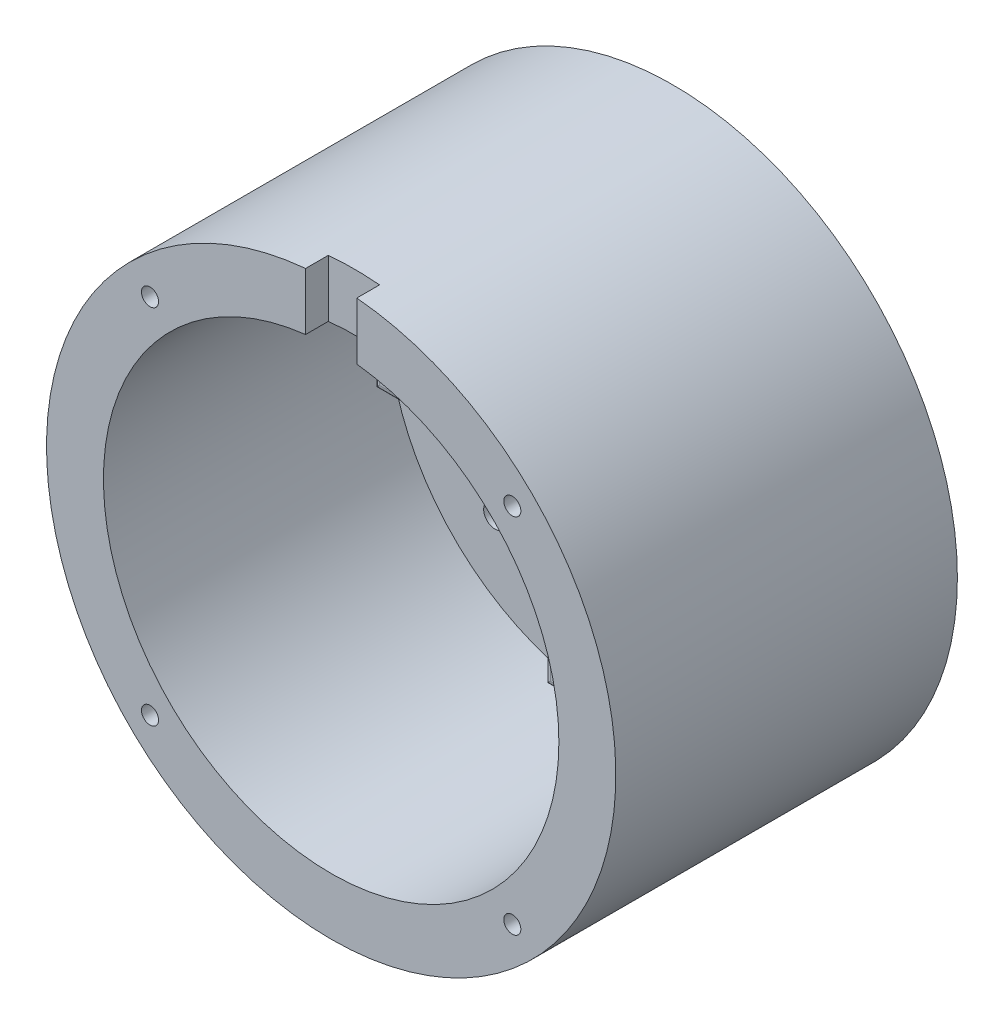
from build123d import *

# Parameters (mm, degrees)
CROQUIS1_R              = 50
CROQUIS1_R_2            = 17.75
SALIENTE_EXTRUIR1_DEPTH = 70
CROQUIS2_R              = 40
CORTAR_EXTRUIR1_DEPTH   = 50
CROQUIS4_R              = 40
CROQUIS4_R_2            = 17.75
CORTAR_EXTRUIR3_DEPTH   = 10
CROQUIS5_R              = 2
CORTAR_EXTRUIR4_DEPTH   = 11
CROQUIS6_R              = 5
CORTAR_EXTRUIR5_DEPTH   = 5
REDONDEO2_R             = 1
CORTAR_EXTRUIR7_START   = -10
CROQUIS8_W              = 9
CROQUIS8_H              = 20
CORTAR_EXTRUIR7_DEPTH   = 4
CROQUIS9_R              = 52.339140615
CORTAR_EXTRUIR8_DEPTH   = 10
CROQUIS10_R             = 1.5
CORTAR_EXTRUIR9_DEPTH   = 30


with BuildPart() as part:
    # Croquis1 → Saliente-Extruir1 (new body)
    with BuildSketch(Plane.XY):
        Circle(CROQUIS1_R)
        Circle(CROQUIS1_R_2, mode=Mode.SUBTRACT)
    extrude(amount=SALIENTE_EXTRUIR1_DEPTH)

    # Croquis2 → Cortar-Extruir1 (cut)
    with BuildSketch(Plane.XY.offset(70)):
        Circle(CROQUIS2_R)
    extrude(amount=-CORTAR_EXTRUIR1_DEPTH, mode=Mode.SUBTRACT)

    # Croquis4 → Cortar-Extruir3 (cut)
    with BuildSketch(Plane.XY.offset(20)):
        Circle(CROQUIS4_R)
        with BuildLine():
            Line((-2.5, 27.386127875), (-2.5, 32.5))
            Line((-2.5, 32.5), (2.5, 32.5))
            Line((2.5, 32.5), (2.5, 27.386127875))
            ThreePointArc((2.5, 27.386127875), (19.445436483, 19.445436483), (27.386127875, 2.5))
            Line((27.386127875, 2.5), (32.5, 2.5))
            Line((32.5, 2.5), (32.5, -2.5))
            Line((32.5, -2.5), (27.386127875, -2.5))
            ThreePointArc((27.386127875, -2.5), (19.445436483, -19.445436483), (2.5, -27.386127875))
            Line((2.5, -27.386127875), (2.5, -32.5))
            Line((2.5, -32.5), (-2.5, -32.5))
            Line((-2.5, -32.5), (-2.5, -27.386127875))
            ThreePointArc((-2.5, -27.386127875), (-19.445436483, -19.445436483), (-27.386127875, -2.5))
            Line((-27.386127875, -2.5), (-32.5, -2.5))
            Line((-32.5, -2.5), (-32.5, 2.5))
            Line((-32.5, 2.5), (-27.386127875, 2.5))
            ThreePointArc((-27.386127875, 2.5), (-19.445436483, 19.445436483), (-2.5, 27.386127875))
        make_face(mode=Mode.SUBTRACT)
        with BuildLine():
            Line((-2.5, 22.5), (-2.5, 27.386127875))
            ThreePointArc((-2.5, 27.386127875), (-19.445436483, 19.445436483), (-27.386127875, 2.5))
            Line((-27.386127875, 2.5), (-22.5, 2.5))
            Line((-22.5, 2.5), (-22.5, -2.5))
            Line((-22.5, -2.5), (-27.386127875, -2.5))
            ThreePointArc((-27.386127875, -2.5), (-19.445436483, -19.445436483), (-2.5, -27.386127875))
            Line((-2.5, -27.386127875), (-2.5, -22.5))
            Line((-2.5, -22.5), (2.5, -22.5))
            Line((2.5, -22.5), (2.5, -27.386127875))
            ThreePointArc((2.5, -27.386127875), (19.445436483, -19.445436483), (27.386127875, -2.5))
            Line((27.386127875, -2.5), (22.5, -2.5))
            Line((22.5, -2.5), (22.5, 2.5))
            Line((22.5, 2.5), (27.386127875, 2.5))
            ThreePointArc((27.386127875, 2.5), (19.445436483, 19.445436483), (2.5, 27.386127875))
            Line((2.5, 27.386127875), (2.5, 22.5))
            Line((2.5, 22.5), (-2.5, 22.5))
        make_face()
        Circle(CROQUIS4_R_2, mode=Mode.SUBTRACT)
    extrude(amount=-CORTAR_EXTRUIR3_DEPTH, mode=Mode.SUBTRACT)

    # Croquis5 → Cortar-Extruir4 (cut, through all)
    with BuildSketch(Plane.XY.offset(10)):
        with Locations((21.213203436, 21.213203436)):
            Circle(CROQUIS5_R)
        with Locations((21.213203436, -21.213203436)):
            Circle(CROQUIS5_R)
        with Locations((-21.213203436, -21.213203436)):
            Circle(CROQUIS5_R)
        with Locations((-21.213203436, 21.213203436)):
            Circle(CROQUIS5_R)
    extrude(amount=-CORTAR_EXTRUIR4_DEPTH, mode=Mode.SUBTRACT)

    # Croquis6 → Cortar-Extruir5 (cut)
    with BuildSketch(Plane(origin=(0, 0, 0), x_dir=(-1, 0, 0), z_dir=(0, 0, -1))):
        with Locations((-21.213203436, 21.213203436)):
            Circle(CROQUIS6_R)
        with Locations((21.486974797, 21.486974797)):
            Circle(CROQUIS6_R)
        with Locations((21.760746158, -21.213203436)):
            Circle(CROQUIS6_R)
        with Locations((-20.939432074, -21.486974797)):
            Circle(CROQUIS6_R)
    extrude(amount=-CORTAR_EXTRUIR5_DEPTH, mode=Mode.SUBTRACT)

    # Redondeo2
    redondeo2_edges = [part.edges().sort_by_distance(p)[0] for p in [
        (-40, 0, 70),
        (-22.5, 0, 20),
        (2.5, -27.5, 20),
        (32.5, 0, 20),
        (27.5, 2.5, 20),
        (-2.5, 27.5, 20),
        (-27.5, -2.5, 20),
        (0, -22.5, 20),
        (0, 22.5, 20),
        (2.5, 27.5, 20),
        (0, 32.5, 20),
        (27.5, -2.5, 20),
        (22.5, 0, 20),
        (-2.5, -27.5, 20),
        (0, -32.5, 20),
        (-32.5, 0, 20),
        (-27.5, 2.5, 20),
        (-50, 0, 70),
    ]]
    fillet(redondeo2_edges, radius=REDONDEO2_R)

    # Croquis8 → Cortar-Extruir7 (cut)
    with BuildSketch(Plane.XY.offset(70).offset(CORTAR_EXTRUIR7_START)):
        with Locations((0, 45)):
            Rectangle(CROQUIS8_W, CROQUIS8_H)
    extrude(amount=-CORTAR_EXTRUIR7_DEPTH, mode=Mode.SUBTRACT)

    # Croquis9 → Cortar-Extruir8 (cut)
    with BuildSketch(Plane.XY.offset(70)):
        Circle(CROQUIS9_R)
    extrude(amount=-CORTAR_EXTRUIR8_DEPTH, mode=Mode.SUBTRACT)

    # Croquis10 → Cortar-Extruir9 (cut)
    with BuildSketch(Plane.XY.offset(60)):
        with Locations((31.819805153, 31.819805153)):
            Circle(CROQUIS10_R)
        with Locations((31.819805153, -31.819805153)):
            Circle(CROQUIS10_R)
        with Locations((-31.819805153, -31.819805153)):
            Circle(CROQUIS10_R)
        with Locations((-31.819805153, 31.819805153)):
            Circle(CROQUIS10_R)
    extrude(amount=-CORTAR_EXTRUIR9_DEPTH, mode=Mode.SUBTRACT)


solid = part.part
